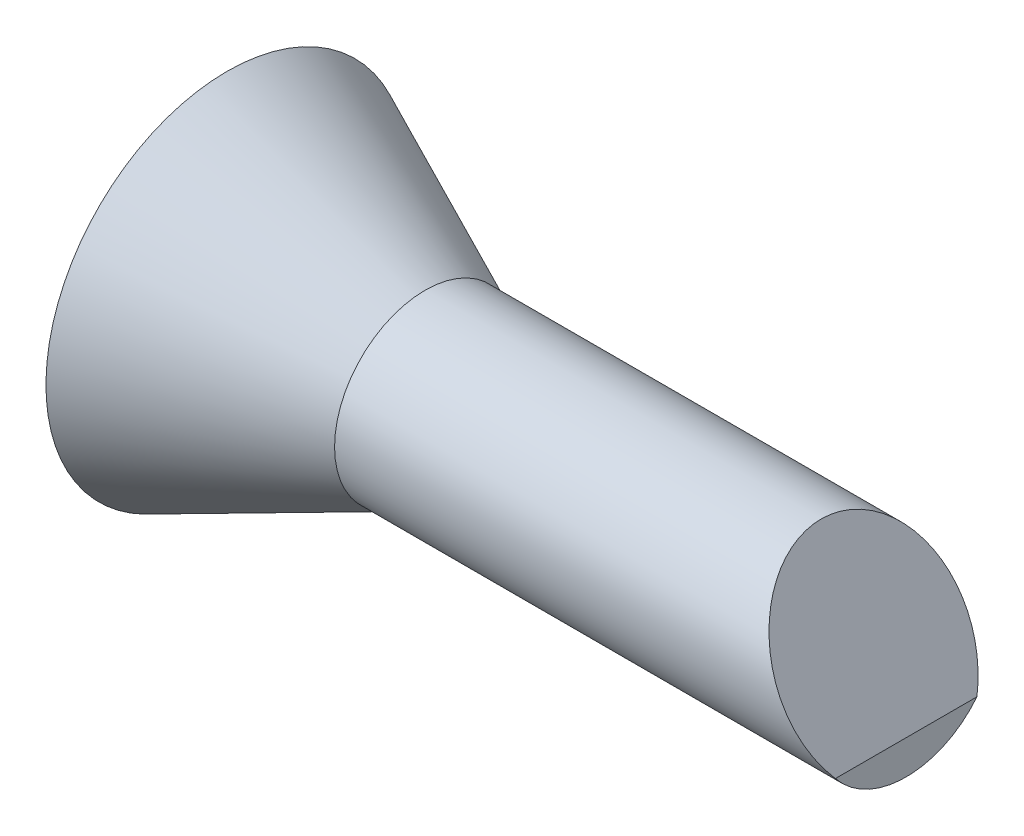
from build123d import *

# Parameters (mm, degrees)
CUT_EXTRUDE1_DEPTH = 30


with BuildPart() as part:
    # Sketch1 → Revolve1 (revolve)
    with BuildSketch(Plane.XY, mode=Mode.PRIVATE) as revolve1_sk:
        Polygon((0, 0), (35, 16), (120, 16), (120, 32), (0, 32), align=None)
    revolve(revolve1_sk.sketch.rotate(Axis((120, 32, 0), (-1, 0, 0)), 180), axis=Axis((120, 32, 0), (-1, 0, 0)))  # turned: the seam where the file's is

    # Sketch2 → Cut-Extrude1 (cut, symmetric)
    with BuildSketch(Plane.XY):
        Polygon((105, 48), (120, 22.019237886), (120, 48), align=None)
    extrude(amount=CUT_EXTRUDE1_DEPTH, both=True, mode=Mode.SUBTRACT)


solid = part.part
